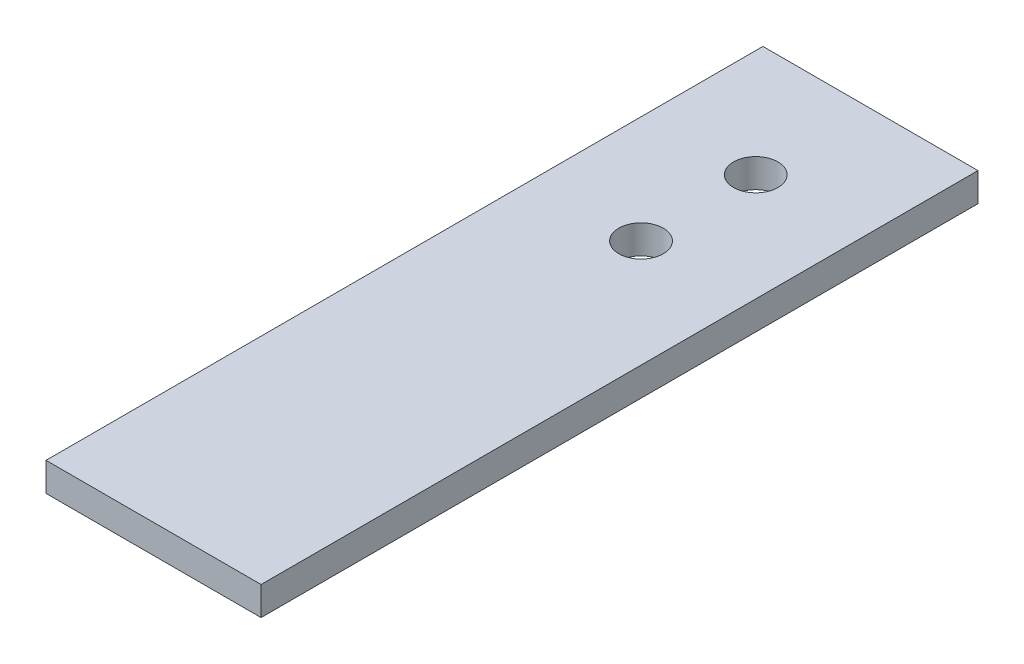
from build123d import *

# Parameters (mm, degrees)
SKETCH_1_W      = 15
SKETCH_1_H      = 50
SKETCH_1_R      = 1.55
EXTRUDE_1_DEPTH = 2


with BuildPart() as part:
    # 草图1 → 凸台-拉伸1 (new body)
    with BuildSketch(Plane(origin=(0, 0, 0), x_dir=(1, 0, 0), z_dir=(0, 1, 0))):
        with Locations((7.5, 25)):
            Rectangle(SKETCH_1_W, SKETCH_1_H)
        with Locations((7.5, 42)):
            Circle(SKETCH_1_R, mode=Mode.SUBTRACT)
        with Locations((7.5, 34)):
            Circle(SKETCH_1_R, mode=Mode.SUBTRACT)
    extrude(amount=EXTRUDE_1_DEPTH)


solid = part.part
